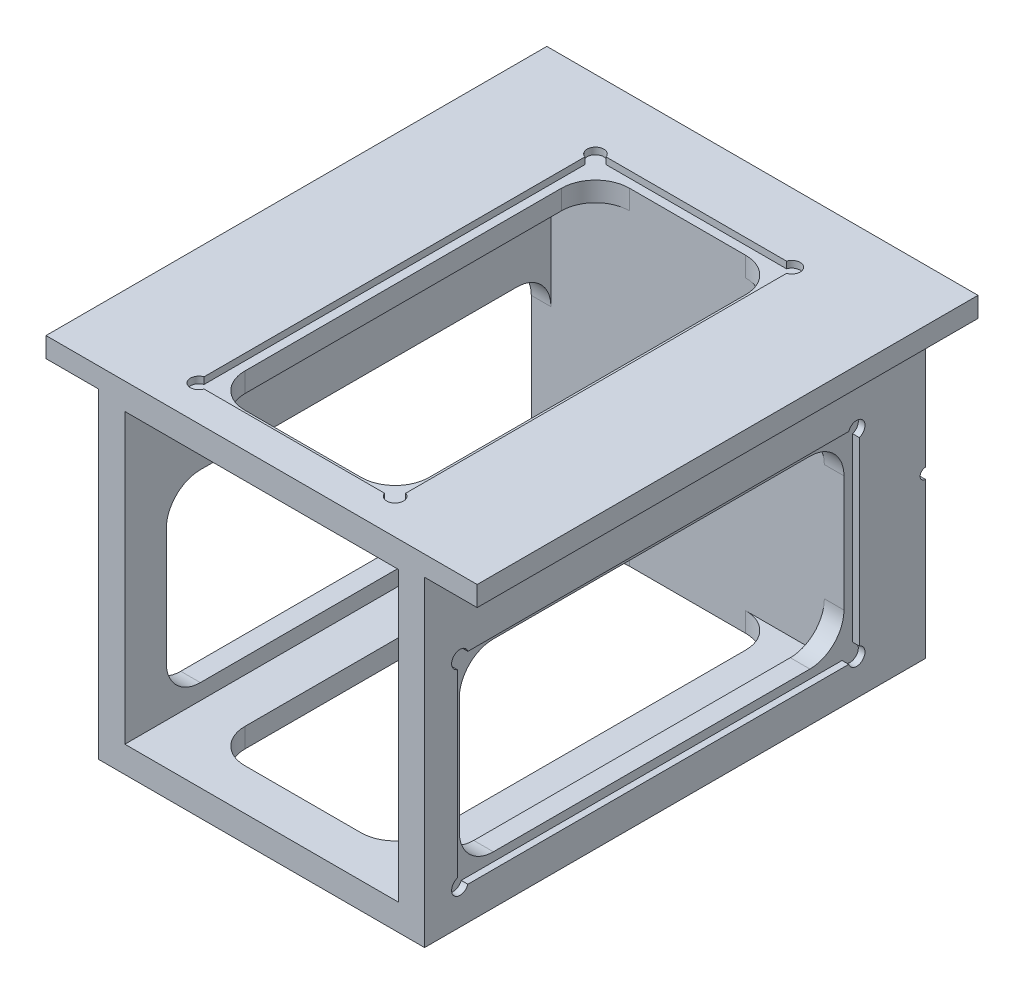
from build123d import *

# Parameters (mm, degrees)
BOSS_EXTRUDE1_DEPTH = 88.9
CUT_EXTRUDE5_DEPTH  = 73
CUT_EXTRUDE6_DEPTH  = 65.81
SKETCH8_W           = 52
SKETCH8_H           = 54.81
CUT_EXTRUDE7_DEPTH  = 15.875
SKETCH12_W          = 52
SKETCH12_H          = 54.81
CUT_EXTRUDE11_DEPTH = 63.5
SKETCH18_W          = 52
SKETCH18_H          = 54.81
CUT_EXTRUDE14_DEPTH = 81.026
BOSS_EXTRUDE2_DEPTH = 6.35
SKETCH20_R          = 2.5527
CUT_EXTRUDE15_DEPTH = 9.525
CUT_EXTRUDE16_DEPTH = 73
CUT_EXTRUDE17_DEPTH = 1.27
CUT_EXTRUDE18_DEPTH = 1.27
CUT_EXTRUDE19_DEPTH = 1.27
CUT_EXTRUDE20_DEPTH = 1.27


with BuildPart() as part:
    # Sketch1 → Boss-Extrude1 (new body)
    with BuildSketch(Plane.XY):
        Polygon((-41, 29.31), (41, 29.31), (41, 25.5), (31, 25.5), (31, -35.5), (-31, -35.5), (-31, 25.5), (-41, 25.5), align=None)
    extrude(amount=BOSS_EXTRUDE1_DEPTH)

    # Sketch6 → Cut-Extrude5 (cut, through all)
    with BuildSketch(Plane.ZY.offset(31)):
        with BuildLine():
            Line((14.351, 7.526), (74.549, 7.526))
            ThreePointArc((74.549, 7.526), (79.128930622, 5.628930622), (81.026, 1.049))
            Line((81.026, 1.049), (81.026, -21.049))
            ThreePointArc((81.026, -21.049), (79.128930622, -25.628930622), (74.549, -27.526))
            Line((74.549, -27.526), (14.351, -27.526))
            ThreePointArc((14.351, -27.526), (9.771069378, -25.628930622), (7.874, -21.049))
            Line((7.874, -21.049), (7.874, 1.049))
            ThreePointArc((7.874, 1.049), (9.771069378, 5.628930622), (14.351, 7.526))
        make_face()
    extrude(amount=-CUT_EXTRUDE5_DEPTH, mode=Mode.SUBTRACT)

    # Sketch7 → Cut-Extrude6 (cut, through all)
    with BuildSketch(Plane(origin=(0, -35.5, 0), x_dir=(0, 0, 1), z_dir=(0, -1, 0))):
        with BuildLine():
            Line((14.351, 17.526), (74.549, 17.526))
            ThreePointArc((74.549, 17.526), (79.128930622, 15.628930622), (81.026, 11.049))
            Line((81.026, 11.049), (81.026, -11.049))
            ThreePointArc((81.026, -11.049), (79.128930622, -15.628930622), (74.549, -17.526))
            Line((74.549, -17.526), (14.351, -17.526))
            ThreePointArc((14.351, -17.526), (9.771069378, -15.628930622), (7.874, -11.049))
            Line((7.874, -11.049), (7.874, 11.049))
            ThreePointArc((7.874, 11.049), (9.771069378, 15.628930622), (14.351, 17.526))
        make_face()
    extrude(amount=-CUT_EXTRUDE6_DEPTH, mode=Mode.SUBTRACT)

    # Sketch8 → Cut-Extrude7 (cut)
    with BuildSketch(Plane.XY.offset(88.9)):
        with Locations((0, -3.095)):
            Rectangle(SKETCH8_W, SKETCH8_H)
    extrude(amount=-CUT_EXTRUDE7_DEPTH, mode=Mode.SUBTRACT)

    # Sketch12 → Cut-Extrude11 (cut)
    with BuildSketch(Plane.XY.offset(88.9)):
        with Locations((0, -3.095)):
            Rectangle(SKETCH12_W, SKETCH12_H)
    extrude(amount=-CUT_EXTRUDE11_DEPTH, mode=Mode.SUBTRACT)

    # Sketch18 → Cut-Extrude14 (cut)
    with BuildSketch(Plane.XY.offset(88.9)):
        with Locations((0, -3.095)):
            Rectangle(SKETCH18_W, SKETCH18_H)
    extrude(amount=-CUT_EXTRUDE14_DEPTH, mode=Mode.SUBTRACT)

    # Sketch19 → Boss-Extrude2 (add)
    with BuildSketch(Plane(origin=(0, 0, 0), x_dir=(-1, 0, 0), z_dir=(0, 0, -1))):
        Polygon((31, 25.5), (41, 25.5), (41, 29.31), (-41, 29.31), (-41, 25.5), (-31, 25.5), (-31, -35.5), (31, -35.5), align=None)
    extrude(amount=BOSS_EXTRUDE2_DEPTH)

    # Sketch20 → Cut-Extrude15 (cut)
    with BuildSketch(Plane(origin=(0, 0, -6.35), x_dir=(-1, 0, 0), z_dir=(0, 0, -1))):
        with Locations((0, -4.844639258)):
            Circle(SKETCH20_R)
    extrude(amount=-CUT_EXTRUDE15_DEPTH, mode=Mode.SUBTRACT)

    # Sketch21 → Cut-Extrude16 (cut, through all)
    with BuildSketch(Plane(origin=(31, 0, 0), x_dir=(0, 0, -1), z_dir=(1, 0, 0))):
        with BuildLine():
            Line((6.35, -4), (6.35, -6))
            ThreePointArc((6.35, -6), (5.35, -5), (6.35, -4))
        make_face()
    extrude(amount=-CUT_EXTRUDE16_DEPTH, mode=Mode.SUBTRACT)

    # Sketch22 → Cut-Extrude17 (cut)
    with BuildSketch(Plane(origin=(0, -35.5, 0), x_dir=(-1, 0, 0), z_dir=(0, -1, 0))):
        with BuildLine():
            Line((-17.164974651, -6.223), (17.164974651, -6.223))
            ThreePointArc((17.164974651, -6.223), (19.791532015, -5.608467985), (19.177, -8.235025349))
            Line((19.177, -8.235025349), (19.177, -80.664974651))
            ThreePointArc((19.177, -80.664974651), (19.791532015, -83.291532015), (17.164974651, -82.677))
            Line((17.164974651, -82.677), (-17.164974651, -82.677))
            ThreePointArc((-17.164974651, -82.677), (-19.791532015, -83.291532015), (-19.177, -80.664974651))
            Line((-19.177, -80.664974651), (-19.177, -8.235025349))
            ThreePointArc((-19.177, -8.235025349), (-19.791532015, -5.608467985), (-17.164974651, -6.223))
        make_face()
    extrude(amount=-CUT_EXTRUDE17_DEPTH, mode=Mode.SUBTRACT)

    # Sketch23 → Cut-Extrude18 (cut)
    with BuildSketch(Plane(origin=(-31, 0, 0), x_dir=(0, 1, 0), z_dir=(-1, 0, 0))):
        with BuildLine():
            Line((-27.164974651, -6.223), (7.164974651, -6.223))
            ThreePointArc((7.164974651, -6.223), (9.791532015, -5.608467985), (9.177, -8.235025349))
            Line((9.177, -8.235025349), (9.177, -80.664974651))
            ThreePointArc((9.177, -80.664974651), (9.791532015, -83.291532015), (7.164974651, -82.677))
            Line((7.164974651, -82.677), (-27.164974651, -82.677))
            ThreePointArc((-27.164974651, -82.677), (-29.791532015, -83.291532015), (-29.177, -80.664974651))
            Line((-29.177, -80.664974651), (-29.177, -8.235025349))
            ThreePointArc((-29.177, -8.235025349), (-29.791532015, -5.608467985), (-27.164974651, -6.223))
        make_face()
    extrude(amount=-CUT_EXTRUDE18_DEPTH, mode=Mode.SUBTRACT)

    # Sketch24 → Cut-Extrude19 (cut)
    with BuildSketch(Plane(origin=(31, 0, 0), x_dir=(0, -1, 0), z_dir=(1, 0, 0))):
        with BuildLine():
            Line((-7.164974651, -6.223), (27.164974651, -6.223))
            ThreePointArc((27.164974651, -6.223), (29.791532015, -5.608467985), (29.177, -8.235025349))
            Line((29.177, -8.235025349), (29.177, -80.664974651))
            ThreePointArc((29.177, -80.664974651), (29.791532015, -83.291532015), (27.164974651, -82.677))
            Line((27.164974651, -82.677), (-7.164974651, -82.677))
            ThreePointArc((-7.164974651, -82.677), (-9.791532015, -83.291532015), (-9.177, -80.664974651))
            Line((-9.177, -80.664974651), (-9.177, -8.235025349))
            ThreePointArc((-9.177, -8.235025349), (-9.791532015, -5.608467985), (-7.164974651, -6.223))
        make_face()
    extrude(amount=-CUT_EXTRUDE19_DEPTH, mode=Mode.SUBTRACT)

    # Sketch25 → Cut-Extrude20 (cut)
    with BuildSketch(Plane(origin=(0, 29.31, 0), x_dir=(1, 0, 0), z_dir=(0, 1, 0))):
        with BuildLine():
            Line((-17.164974651, -6.223), (17.164974651, -6.223))
            ThreePointArc((17.164974651, -6.223), (19.791532015, -5.608467985), (19.177, -8.235025349))
            Line((19.177, -8.235025349), (19.177, -80.664974651))
            ThreePointArc((19.177, -80.664974651), (19.791532015, -83.291532015), (17.164974651, -82.677))
            Line((17.164974651, -82.677), (-17.164974651, -82.677))
            ThreePointArc((-17.164974651, -82.677), (-19.791532015, -83.291532015), (-19.177, -80.664974651))
            Line((-19.177, -80.664974651), (-19.177, -8.235025349))
            ThreePointArc((-19.177, -8.235025349), (-19.791532015, -5.608467985), (-17.164974651, -6.223))
        make_face()
    extrude(amount=-CUT_EXTRUDE20_DEPTH, mode=Mode.SUBTRACT)


solid = part.part
